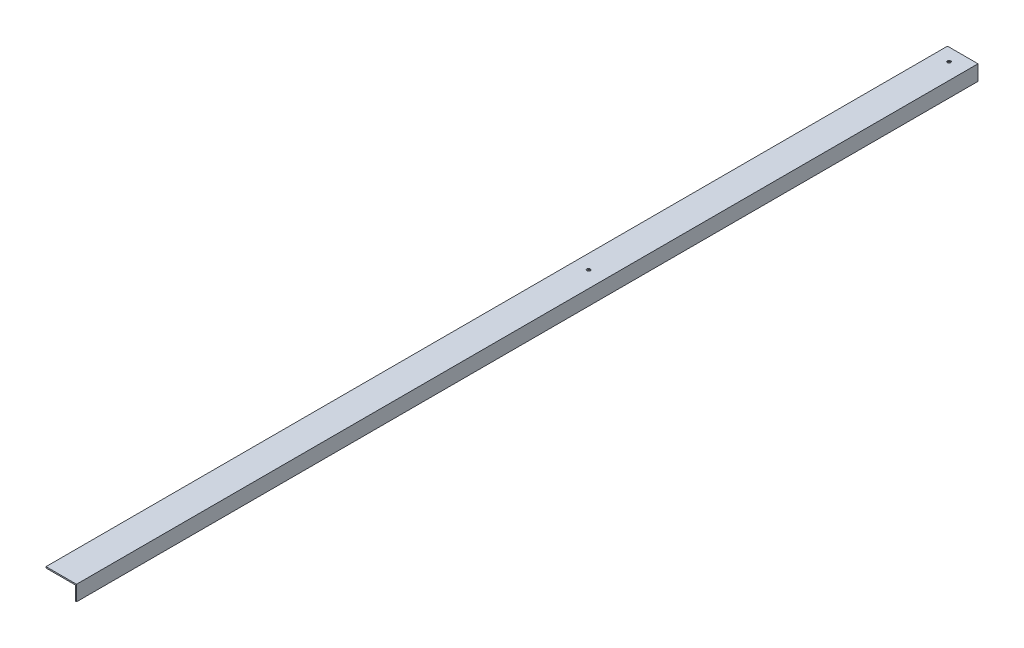
from build123d import *

# Parameters (mm, degrees)
EXTRUDE_THIN1_DEPTH            = 1125.4359
F_4_CLEARANCE_HOLE1_AT_2_COUNT = 2
F_4_CLEARANCE_HOLE1_AT_2_PITCH = 450


with BuildPart() as part:
    # Sketch1 → Extrude-Thin1 (new body)
    with BuildSketch(Plane.XY):
        Polygon((-38.1, 0), (0, 0), (0, -19.05), (-1.5748, -19.05), (-1.5748, -1.5748), (-38.1, -1.5748), align=None)
    extrude(amount=EXTRUDE_THIN1_DEPTH)

    # Sketch2 → #4 Clearance Hole1 (revolve, cut)
    with BuildSketch(Plane(origin=(-20.32, 0, 15.875), x_dir=(0, 0, 1), z_dir=(1, 0, 0))):
        Polygon((0, 0), (0, 1.5748), (2.1082, 1.5748), (1.4732, 0.9398), (1.4732, 0.635), (2.1082, 0), align=None)
    f_4_clearance_hole1 = revolve(axis=Axis((-20.32, 6.35, 15.875), (0, -1, 0)), mode=Mode.SUBTRACT)

    # #4 Clearance Hole1 at 2: #4 Clearance Hole1 ×2
    with Locations(*[(0, 0, i * F_4_CLEARANCE_HOLE1_AT_2_PITCH) for i in range(1, F_4_CLEARANCE_HOLE1_AT_2_COUNT)]):
        add(f_4_clearance_hole1, mode=Mode.SUBTRACT)


solid = part.part
